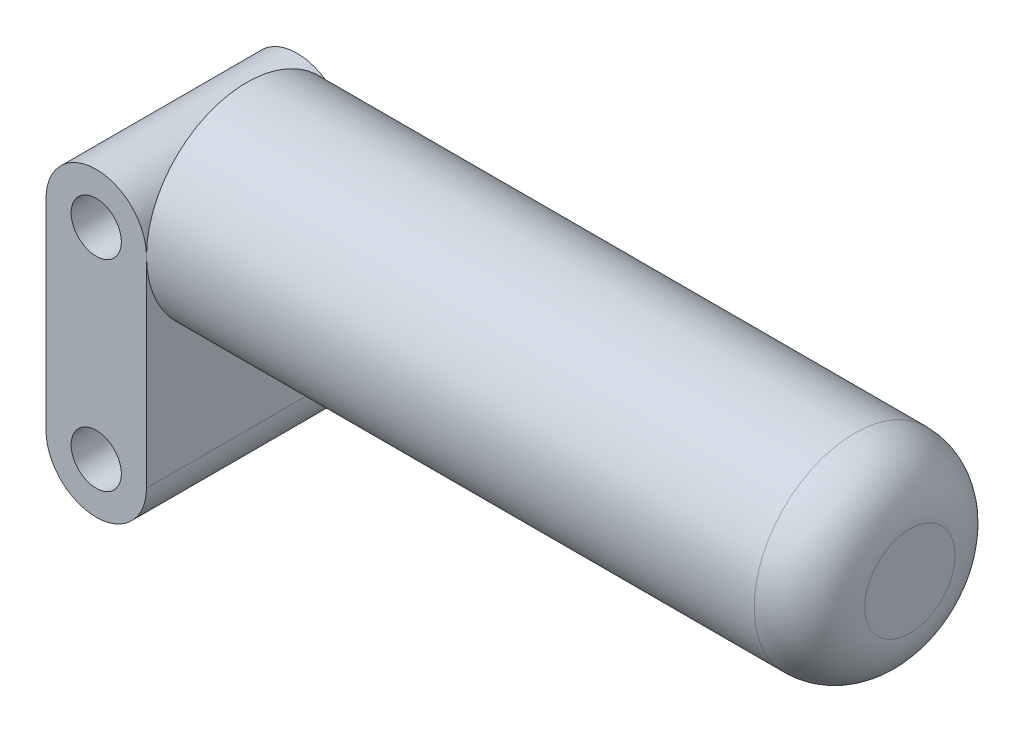
from build123d import *

# Parameters (mm, degrees)
ESQUISSE1_R        = 2.5
BOSS_EXTRU_1_DEPTH = 10
ESQUISSE2_R        = 10
BOSS_EXTRU_2_DEPTH = 66
CONG_1_R           = 5.5


with BuildPart() as part:
    # Esquisse1 → Boss.-Extru.1 (new, symmetric)
    with BuildSketch(Plane.XY):
        with BuildLine():
            Line((5, 10), (5, -10))
            ThreePointArc((5, -10), (0, -15), (-5, -10))
            Line((-5, -10), (-5, 10))
            ThreePointArc((-5, 10), (0, 15), (5, 10))
        make_face()
        with Locations((0, 10)):
            Circle(ESQUISSE1_R, mode=Mode.SUBTRACT)
        with Locations((0, -10)):
            Circle(ESQUISSE1_R, mode=Mode.SUBTRACT)
    extrude(amount=BOSS_EXTRU_1_DEPTH, both=True)

    # Esquisse2 → Boss.-Extru.2 (add)
    with BuildSketch(Plane(origin=(5, 0, 0), x_dir=(0, 0, -1), z_dir=(1, 0, 0))):
        with Locations((0, 10)):
            Circle(ESQUISSE2_R)
    extrude(amount=BOSS_EXTRU_2_DEPTH)

    # Congé1
    cong_1_edges = [part.edges().sort_by_distance(p)[0] for p in [
        (71, 10, 10),
    ]]
    fillet(cong_1_edges, radius=CONG_1_R)


solid = part.part
